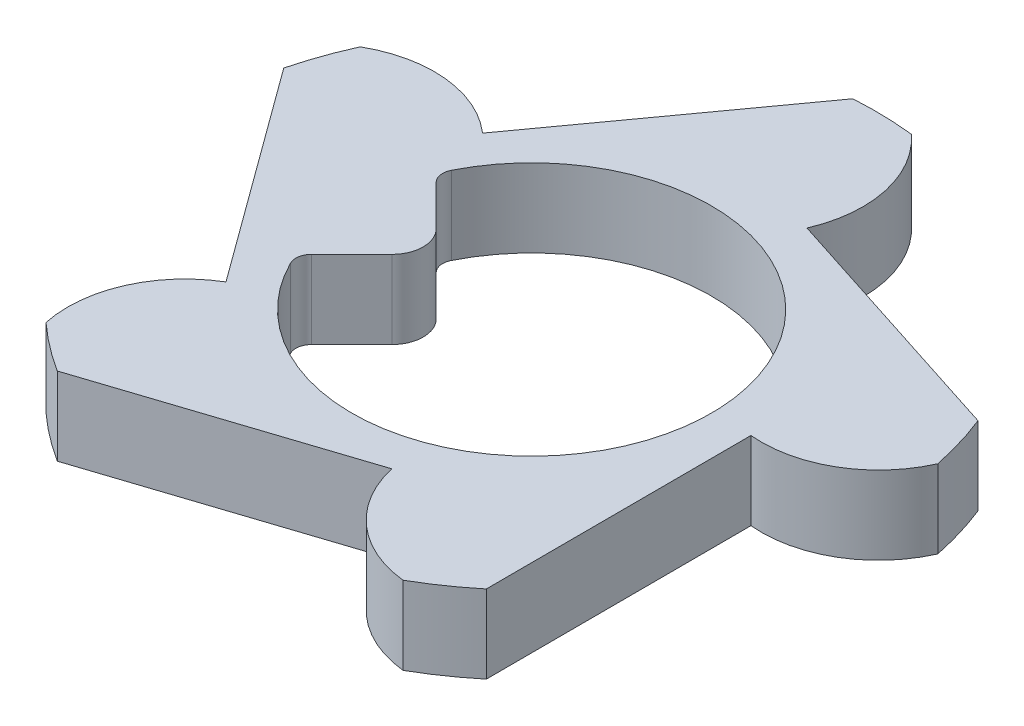
from build123d import *

# Parameters (mm, degrees)
BOSS_EXTRUDE1_DEPTH = 0.5
CUT_EXTRUDE1_REACH  = 2.5
FILLET1_R           = 0.1
FILLET2_R           = 0.2


with BuildPart() as part:
    # Sketch1 → Boss-Extrude1 (new body)
    with BuildSketch(Plane(origin=(0, 0, 0), x_dir=(1, 0, 0), z_dir=(0, 1, 0))):
        with BuildLine():
            Line((-1.130713076, -0.825522828), (-2.131397859, 0.545108401))
            ThreePointArc((-2.131397859, 0.545108401), (-2.07578756, 0.7287702), (-2.004384052, 0.906887298))
            ThreePointArc((-2.004384052, 0.906887298), (-1.555532522, 1.003410855), (-1.134528421, 0.820271456))
            Line((-1.134528421, 0.820271456), (-0.140209263, 2.195527582))
            ThreePointArc((-0.140209263, 2.195527582), (0.051648015, 2.199393662), (0.243112339, 2.186526101))
            ThreePointArc((0.243112339, 2.186526101), (0.473614448, 1.789470348), (0.42953595, 1.332478468))
            Line((0.42953595, 1.332478468), (2.044743768, 0.811802268))
            ThreePointArc((2.044743768, 0.811802268), (2.107707789, 0.630529838), (2.154635741, 0.444460149))
            ThreePointArc((2.154635741, 0.444460149), (1.848242349, 0.102542642), (1.399996238, 0.003245527))
            Line((1.399996238, 0.003245527), (1.40393041, -1.693806188))
            ThreePointArc((1.40393041, -1.693806188), (1.250987037, -1.809704792), (1.088525782, -1.911834622))
            ThreePointArc((1.088525782, -1.911834622), (0.668662143, -1.726095511), (0.435709309, -1.330472622))
            Line((0.435709309, -1.330472622), (-1.177067057, -1.858632063))
            ThreePointArc((-1.177067057, -1.858632063), (-1.33455528, -1.748988909), (-1.48188981, -1.626038927))
            ThreePointArc((-1.48188981, -1.626038927), (-1.434986417, -1.169328335), (-1.130713076, -0.825522828))
        make_face()
    extrude(amount=BOSS_EXTRUDE1_DEPTH)

    # Sketch2 → Cut-Extrude1 (cut, up to next)
    with BuildSketch(Plane(origin=(0, 0.5, 0), x_dir=(1, 0, 0), z_dir=(0, 1, 0)), mode=Mode.PRIVATE) as cut_extrude1_sk1:
        with BuildLine():
            Line((-1.059104505, 0.448104505), (-0.611, 0))
            Line((-0.611, 0), (-1.059104505, -0.448104505))
            ThreePointArc((-1.059104505, -0.448104505), (1.15, 0), (-1.059104505, 0.448104505))
        make_face()
    cut_extrude1_tool1 = extrude(cut_extrude1_sk1.sketch, amount=-CUT_EXTRUDE1_REACH, mode=Mode.PRIVATE) & part.part
    add(cut_extrude1_tool1.solids().sort_by_distance((0.062233, 0.5, 0))[0], mode=Mode.SUBTRACT)

    # Fillet1
    fillet1_edges = [part.edges().sort_by_distance(p)[0] for p in [
        (-1.059104505, 0.25, -0.448104505),
        (-1.059104505, 0.25, 0.448104505),
    ]]
    fillet(fillet1_edges, radius=FILLET1_R)

    # Fillet2
    fillet2_edges = [part.edges().sort_by_distance(p)[0] for p in [
        (-0.611, 0.25, 0),
    ]]
    fillet(fillet2_edges, radius=FILLET2_R)


solid = part.part
